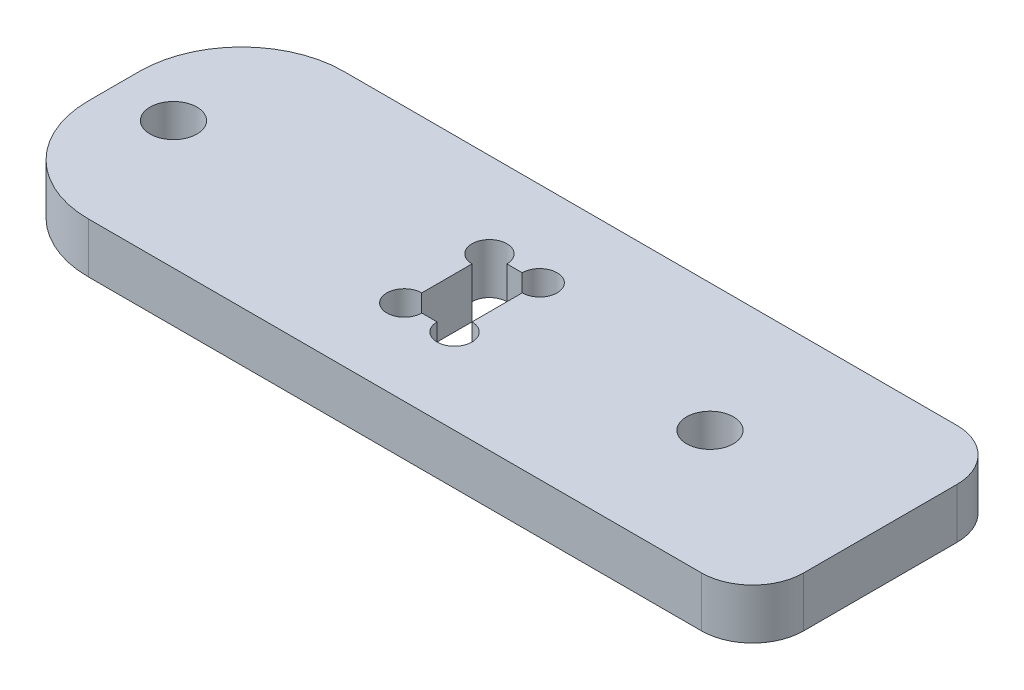
from build123d import *
from OCP.BRepFilletAPI import BRepFilletAPI_MakeFillet

# Parameters (mm, degrees)
SKETCH1_W           = 90
SKETCH1_H           = 30
BOSS_EXTRUDE1_DEPTH = 5.9
SKETCH2_R           = 2.75
CUT_EXTRUDE1_DEPTH  = 10
SKETCH3_W           = 5.9
SKETCH3_H           = 10
CUT_EXTRUDE2_DEPTH  = 10
CUT_EXTRUDE5_REACH  = 49.8
SKETCH6_R           = 2.05
FILLET1_R1          = 12
FILLET1_R2          = 6


with BuildPart() as part:
    # Sketch1 → Boss-Extrude1 (new body)
    with BuildSketch(Plane(origin=(0, 0, 0), x_dir=(1, 0, 0), z_dir=(0, 1, 0))):
        Rectangle(SKETCH1_W, SKETCH1_H)
    extrude(amount=BOSS_EXTRUDE1_DEPTH)

    # Sketch2 → Cut-Extrude1 (cut)
    with BuildSketch(Plane(origin=(0, 5.9, 0), x_dir=(1, 0, 0), z_dir=(0, 1, 0))):
        with Locations((25, 0)):
            Circle(SKETCH2_R)
        with Locations((-38, 0)):
            Circle(SKETCH2_R)
    extrude(amount=-CUT_EXTRUDE1_DEPTH, mode=Mode.SUBTRACT)

    # Sketch3 → Cut-Extrude2 (cut)
    with BuildSketch(Plane(origin=(0, 5.9, 0), x_dir=(1, 0, 0), z_dir=(0, 1, 0))):
        with Locations((-2.95, 0)):
            Rectangle(SKETCH3_W, SKETCH3_H)
    extrude(amount=-CUT_EXTRUDE2_DEPTH, mode=Mode.SUBTRACT)

    # Sketch6 → Cut-Extrude5 (cut, up to next)
    with BuildSketch(Plane(origin=(0, 5.9, 0), x_dir=(1, 0, 0), z_dir=(0, 1, 0)), mode=Mode.PRIVATE) as cut_extrude5_sk1:
        with Locations((0, 5)):
            Circle(SKETCH6_R)
    cut_extrude5_tool1 = extrude(cut_extrude5_sk1.sketch, amount=-CUT_EXTRUDE5_REACH, mode=Mode.PRIVATE) & part.part
    # Sketch6 → Cut-Extrude5 (cut, up to next)
    with BuildSketch(Plane(origin=(0, 5.9, 0), x_dir=(1, 0, 0), z_dir=(0, 1, 0)), mode=Mode.PRIVATE) as cut_extrude5_sk2:
        with Locations((-5.9, 5)):
            Circle(SKETCH6_R)
    cut_extrude5_tool2 = extrude(cut_extrude5_sk2.sketch, amount=-CUT_EXTRUDE5_REACH, mode=Mode.PRIVATE) & part.part
    # Sketch6 → Cut-Extrude5 (cut, up to next)
    with BuildSketch(Plane(origin=(0, 5.9, 0), x_dir=(1, 0, 0), z_dir=(0, 1, 0)), mode=Mode.PRIVATE) as cut_extrude5_sk3:
        with Locations((0, -5)):
            Circle(SKETCH6_R)
    cut_extrude5_tool3 = extrude(cut_extrude5_sk3.sketch, amount=-CUT_EXTRUDE5_REACH, mode=Mode.PRIVATE) & part.part
    # Sketch6 → Cut-Extrude5 (cut, up to next)
    with BuildSketch(Plane(origin=(0, 5.9, 0), x_dir=(1, 0, 0), z_dir=(0, 1, 0)), mode=Mode.PRIVATE) as cut_extrude5_sk4:
        with Locations((-5.9, -5)):
            Circle(SKETCH6_R)
    cut_extrude5_tool4 = extrude(cut_extrude5_sk4.sketch, amount=-CUT_EXTRUDE5_REACH, mode=Mode.PRIVATE) & part.part
    add(cut_extrude5_tool1.solids().sort_by_distance((0, 5.9, -5))[0], mode=Mode.SUBTRACT)
    add(cut_extrude5_tool2.solids().sort_by_distance((-5.9, 5.9, -5))[0], mode=Mode.SUBTRACT)
    add(cut_extrude5_tool3.solids().sort_by_distance((0, 5.9, 5))[0], mode=Mode.SUBTRACT)
    add(cut_extrude5_tool4.solids().sort_by_distance((-5.9, 5.9, 5))[0], mode=Mode.SUBTRACT)

    # Fillet1: one fillet with a radius per group of edges: ONE call of the kernel's fillet builder (fillet() takes one radius for all edges)
    fillet1_edges_1 = [part.edges().sort_by_distance(p)[0] for p in [
        (-45, 2.95, -15),
        (-45, 2.95, 15),
    ]]
    fillet1_edges_2 = [part.edges().sort_by_distance(p)[0] for p in [
        (45, 2.95, 15),
        (45, 2.95, -15),
    ]]
    fillet1 = BRepFilletAPI_MakeFillet(part.part.solid().wrapped)
    for e in fillet1_edges_1:
        fillet1.Add(FILLET1_R1, e.wrapped)
    for e in fillet1_edges_2:
        fillet1.Add(FILLET1_R2, e.wrapped)
    add(Compound.cast(fillet1.Shape()), mode=Mode.REPLACE)


solid = part.part
